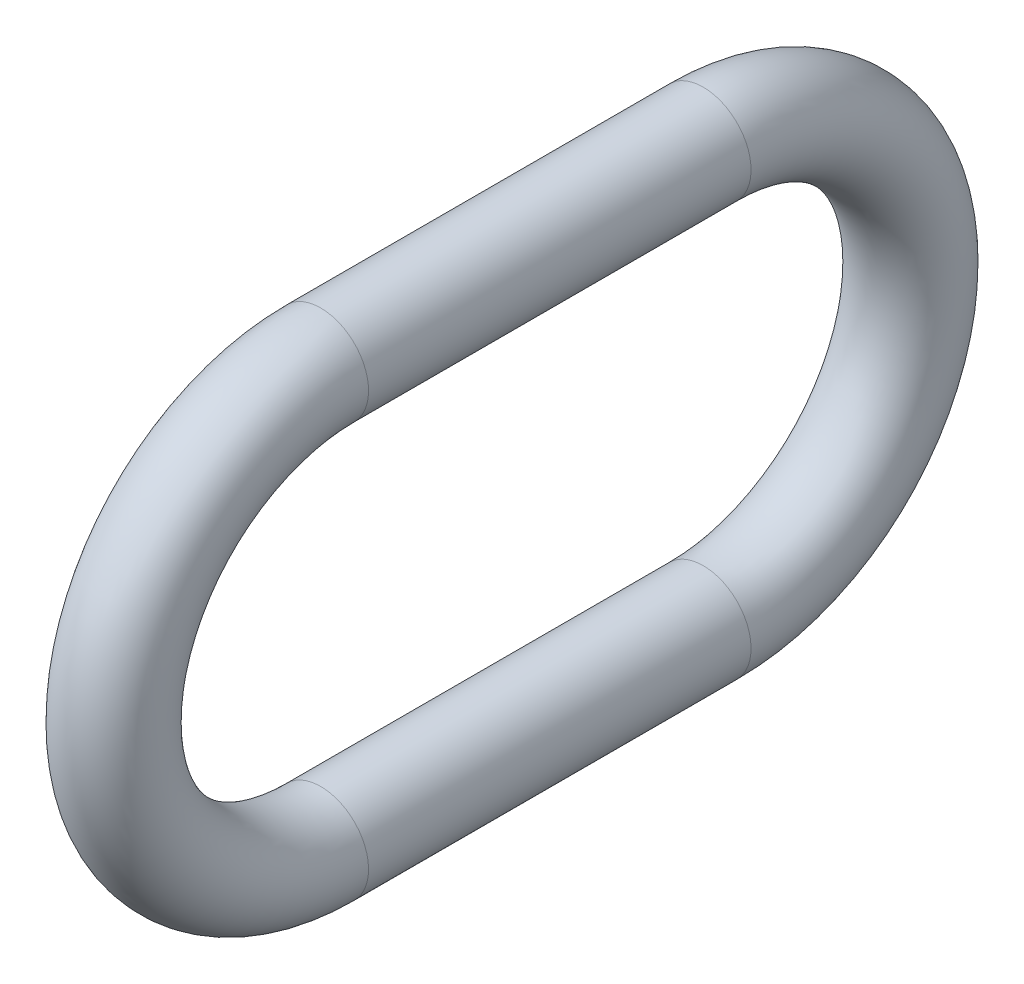
from build123d import *

# Parameters (mm, degrees)
SWEEP1_PROFILE_R = 2.38125


with BuildPart() as part:
    # Sweep1: sweep along a path in Sketch1
    with BuildLine(Plane(origin=(0, 0, 0), x_dir=(0, 0, -1), z_dir=(1, 0, 0))) as sweep1_path:
        Line((31.75, -10.31875), (12.7, -10.31875))
        ThreePointArc((12.7, -10.31875), (2.38125, 0), (12.7, 10.31875))
        Line((12.7, 10.31875), (31.75, 10.31875))
        ThreePointArc((31.75, 10.31875), (42.06875, 0), (31.75, -10.31875))
    # Sweep1 profile (on start of the path) → Sweep1 (sweep)
    with BuildSketch(Plane(origin=(0, -10.31875, -31.75), x_dir=(1, 0, 0), z_dir=(0, 0, 1))):
        Circle(SWEEP1_PROFILE_R)
    sweep(path=sweep1_path.line)


solid = part.part
